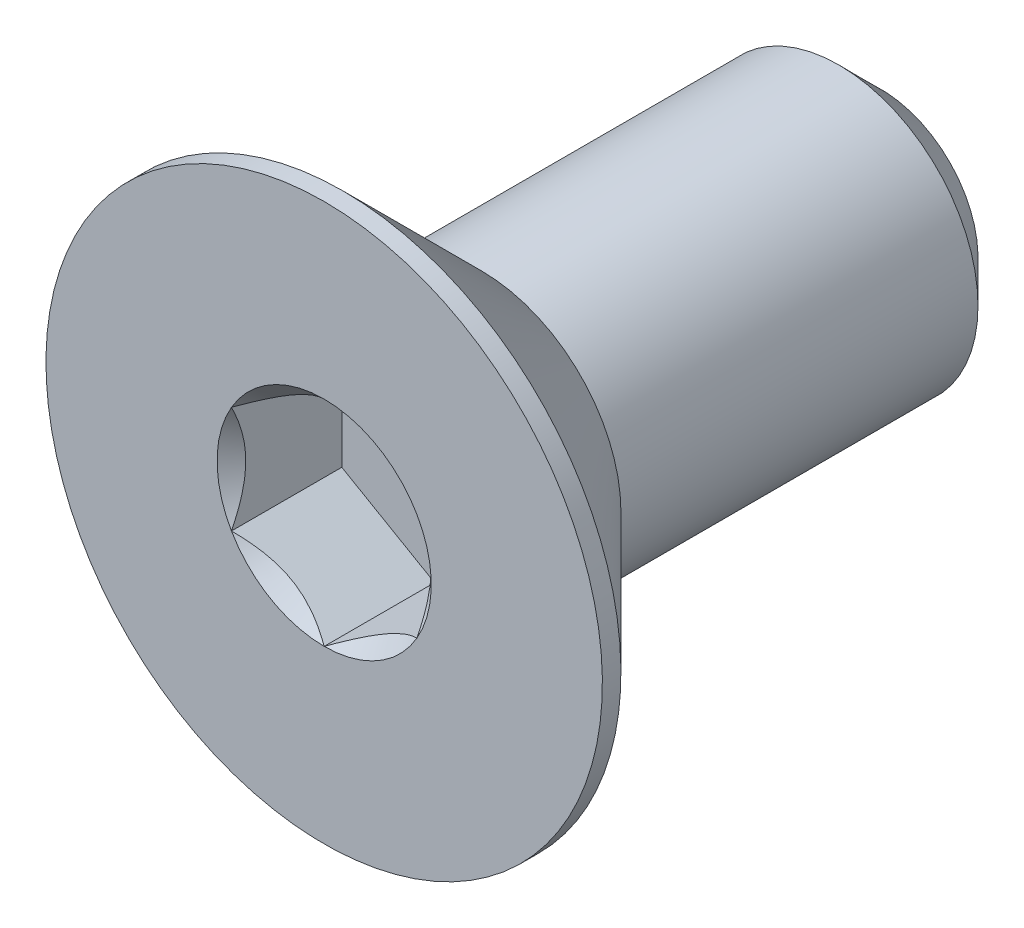
from build123d import *

# Parameters (mm, degrees)
SKETCH3_W          = 6
SKETCH3_H          = 1.5
CHAMFER1_SIZE      = 0.45
CUT_EXTRUDE1_DEPTH = 1.19


with BuildPart() as part:
    # Sketch3 → Revolve1 (revolve)
    with BuildSketch(Plane(origin=(0, 0, 0), x_dir=(0, 0, -1), z_dir=(1, 0, 0))):
        with Locations((0, 0.75)):
            Rectangle(SKETCH3_W, SKETCH3_H)
    revolve(axis=Axis((0, 0, -3), (0, 0, 1)))

    # Chamfer1
    chamfer1_edges = [part.edges().sort_by_distance(p)[0] for p in [
        (0, -1.5, -3),
    ]]
    chamfer(chamfer1_edges, length=CHAMFER1_SIZE)

    # Sketch6 → Revolve2 (revolve)
    with BuildSketch(Plane(origin=(0, 0, 0), x_dir=(0, 0, -1), z_dir=(1, 0, 0))):
        Polygon((-3, 3), (-2.8, 3), (-1.3, 1.5), (-1.3, 0), (-3, 0), align=None)
    revolve(axis=Axis((0, 0, -3), (0, 0, 1)))

    # Sketch8 → Cut-Extrude1 (cut)
    with BuildSketch(Plane.XY.offset(3)):
        Polygon((0, 1.154700538), (-1, 0.577350269), (-1, -0.577350269), (0, -1.154700538), (1, -0.577350269), (1, 0.577350269), align=None)
    extrude(amount=-CUT_EXTRUDE1_DEPTH, mode=Mode.SUBTRACT)

    # Cut-Extrude2 cone 1 section (through the dimple's axis) → Cut-Extrude2 (revolve, cut)
    with BuildSketch(Plane(origin=(0, 0, 3), x_dir=(0, -1, 0), z_dir=(1, 0, 0))):
        Polygon((0, 0), (1.154700538, 0), (0, 1.154700538), align=None)
    revolve(axis=Axis((0, 0, 3), (0, 0, -1)), mode=Mode.SUBTRACT)


solid = part.part
